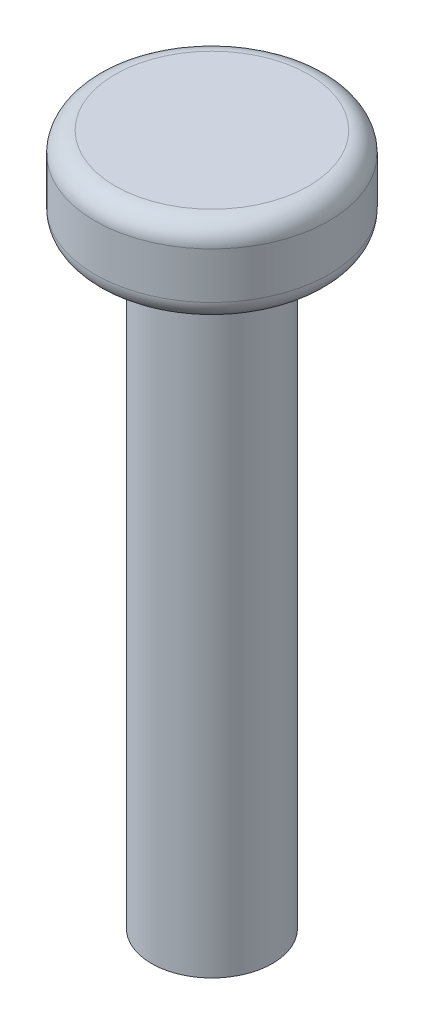
from build123d import *

# Parameters (mm, degrees)
SKETCH1_R           = 3
BOSS_EXTRUDE1_DEPTH = 30
SKETCH2_R           = 5.8
BOSS_EXTRUDE2_DEPTH = 4.3
FILLET1_R           = 1


with BuildPart() as part:
    # Sketch1 → Boss-Extrude1 (new body)
    with BuildSketch(Plane(origin=(0, 0, 0), x_dir=(1, 0, 0), z_dir=(0, 1, 0))):
        with Locations(Location((0, 0, 0), (0, 0, 270))):  # turned: the seam where the file's is
            Circle(SKETCH1_R)
    extrude(amount=BOSS_EXTRUDE1_DEPTH)

    # Sketch2 → Boss-Extrude2 (add)
    with BuildSketch(Plane(origin=(0, 30, 0), x_dir=(1, 0, 0), z_dir=(0, 1, 0))):
        with Locations(Location((0, 0, 0), (0, 0, 270))):  # turned: the seam where the file's is
            Circle(SKETCH2_R)
    extrude(amount=BOSS_EXTRUDE2_DEPTH)

    # Fillet1
    fillet1_edges = [part.edges().sort_by_distance(p)[0] for p in [
        (0, 30, -5.8),
        (0, 34.3, -5.8),
    ]]
    fillet(fillet1_edges, radius=FILLET1_R)


solid = part.part
